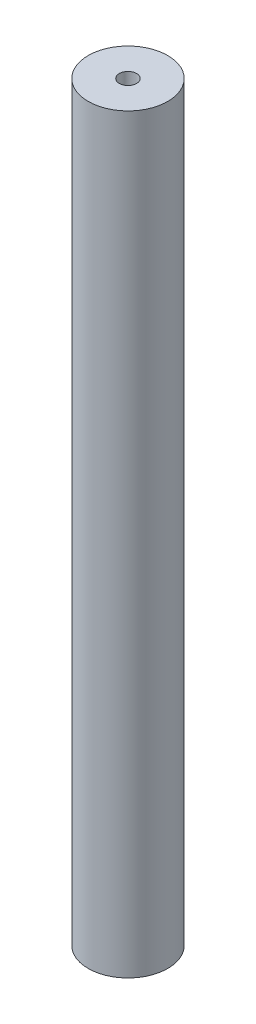
from build123d import *

# Parameters (mm, degrees)
SKETCH1_R                 = 7.9375
BOSS_EXTRUDE1_DEPTH       = 149.86
F_8_32_TAPPED_HOLE3_D     = 3.4544
F_8_32_TAPPED_HOLE3_DEPTH = 12.7
F_8_32_TAPPED_HOLE3_TIP   = 1.037806461
F_8_32_TAPPED_HOLE4_D     = 3.4544
F_8_32_TAPPED_HOLE4_DEPTH = 12.7
F_8_32_TAPPED_HOLE4_TIP   = 1.037806461


with BuildPart() as part:
    # Sketch1 → Boss-Extrude1 (new body)
    with BuildSketch(Plane(origin=(0, 0, 0), x_dir=(1, 0, 0), z_dir=(0, 1, 0))):
        Circle(SKETCH1_R)
    extrude(amount=BOSS_EXTRUDE1_DEPTH)

    # #8-32 Tapped Hole3
    with Locations(Plane(origin=(0, 0, 0), x_dir=(-1, 0, 0), z_dir=(0, -1, 0))):
        with Locations((0, 0)):
            Hole(F_8_32_TAPPED_HOLE3_D / 2, depth=F_8_32_TAPPED_HOLE3_DEPTH)
            with Locations((0, 0, -(F_8_32_TAPPED_HOLE3_DEPTH + F_8_32_TAPPED_HOLE3_TIP / 2))):  # 118° drill point
                Cone(0, F_8_32_TAPPED_HOLE3_D / 2, F_8_32_TAPPED_HOLE3_TIP, mode=Mode.SUBTRACT)

    # #8-32 Tapped Hole4
    with Locations(Plane(origin=(0, 149.86, 0), x_dir=(1, 0, 0), z_dir=(0, 1, 0))):
        with Locations((0, 0)):
            Hole(F_8_32_TAPPED_HOLE4_D / 2, depth=F_8_32_TAPPED_HOLE4_DEPTH)
            with Locations((0, 0, -(F_8_32_TAPPED_HOLE4_DEPTH + F_8_32_TAPPED_HOLE4_TIP / 2))):  # 118° drill point
                Cone(0, F_8_32_TAPPED_HOLE4_D / 2, F_8_32_TAPPED_HOLE4_TIP, mode=Mode.SUBTRACT)


solid = part.part
